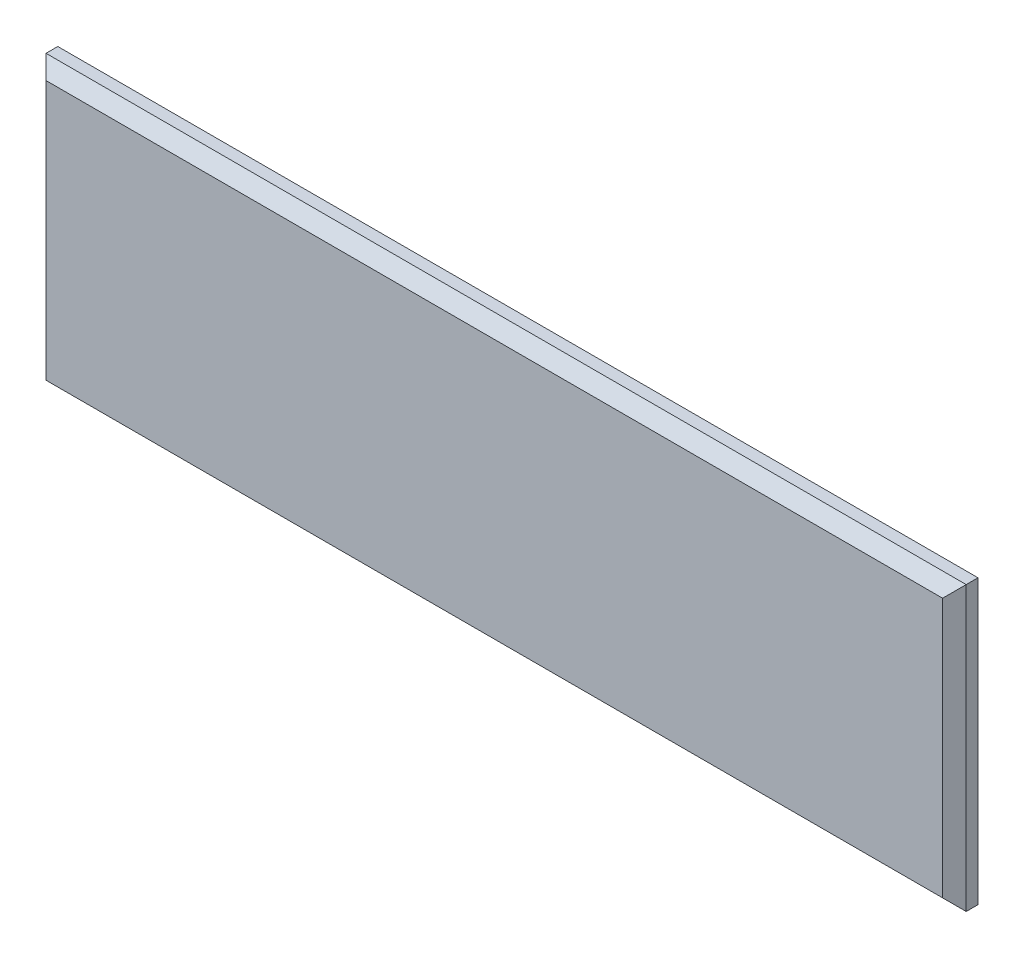
from build123d import *

# Parameters (mm, degrees)
PROFILE_SKETCH_W      = 990.6
PROFILE_SKETCH_H      = 304.8
PROFILE_EXTRUDE_DEPTH = 25.4
EDGE_CHAMFER_SIZE     = 12.7


with BuildPart() as part:
    # Profile Sketch → Profile Extrude (new body)
    with BuildSketch(Plane.XY):
        Rectangle(PROFILE_SKETCH_W, PROFILE_SKETCH_H)
    extrude(amount=PROFILE_EXTRUDE_DEPTH)

    # Edge Chamfer
    edge_chamfer_edges = [part.edges().sort_by_distance(p)[0] for p in [
        (-495.3, 0, 25.4),
        (0, -152.4, 25.4),
        (495.3, 0, 25.4),
        (0, 152.4, 25.4),
    ]]
    chamfer(edge_chamfer_edges, length=EDGE_CHAMFER_SIZE)


solid = part.part
